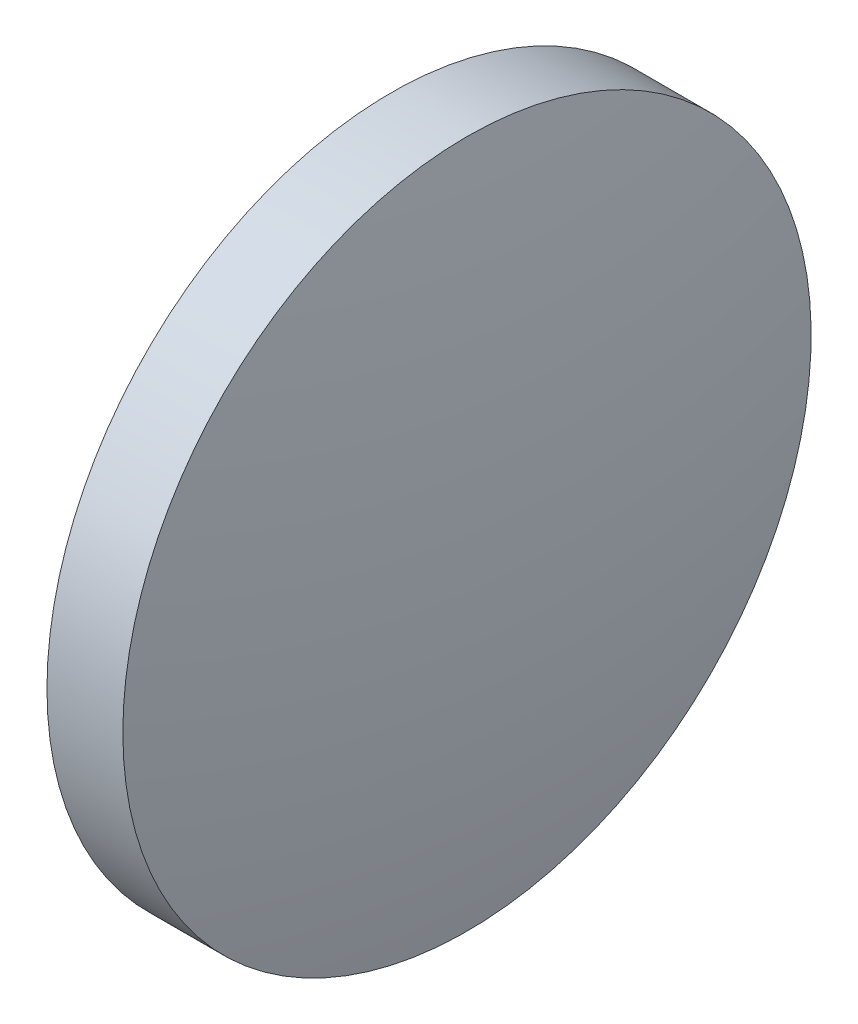
from build123d import *


with BuildPart() as part:
    # 草图1 → 旋转1 (revolve)
    with BuildSketch(Plane.XY):
        with BuildLine():
            Line((195.536860058, 18.732372178), (195.536860058, 25.082372178))
            Line((195.536860058, 25.082372178), (196.936860058, 25.082372178))
            ThreePointArc((196.936860058, 25.082372178), (197.386526744, 21.921513912), (197.536860058, 18.732372178))
            Line((197.536860058, 18.732372178), (195.536860058, 18.732372178))
        make_face()
    revolve(axis=Axis((192.66775104, 18.732372178, 0), (1, 0, 0)))


solid = part.part
